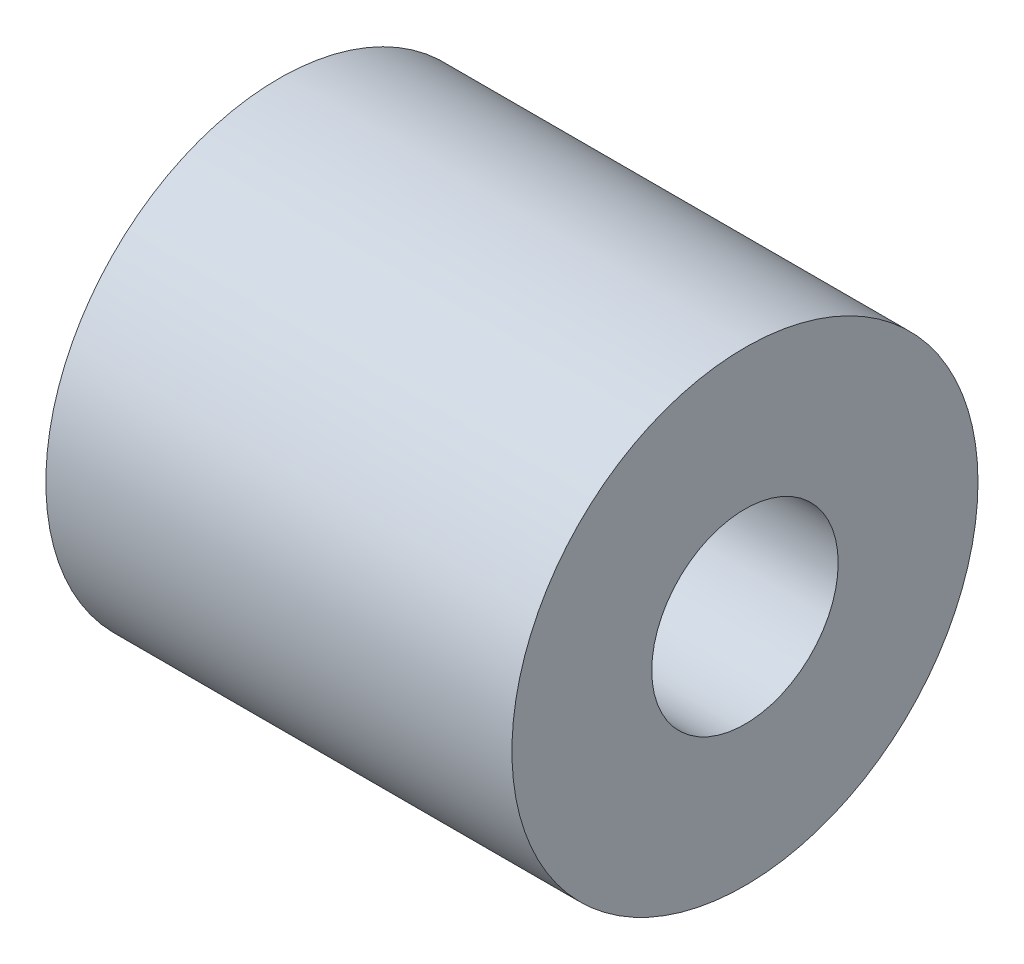
from build123d import *

# Parameters (mm, degrees)
SKETCH2_R           = 5
SKETCH2_R_2         = 2
BOSS_EXTRUDE1_DEPTH = 10


with BuildPart() as part:
    # Sketch2 → Boss-Extrude1 (new body)
    with BuildSketch(Plane(origin=(0, 0, 0), x_dir=(0, 0, -1), z_dir=(1, 0, 0))):
        Circle(SKETCH2_R)
        Circle(SKETCH2_R_2, mode=Mode.SUBTRACT)
    extrude(amount=BOSS_EXTRUDE1_DEPTH)


solid = part.part
